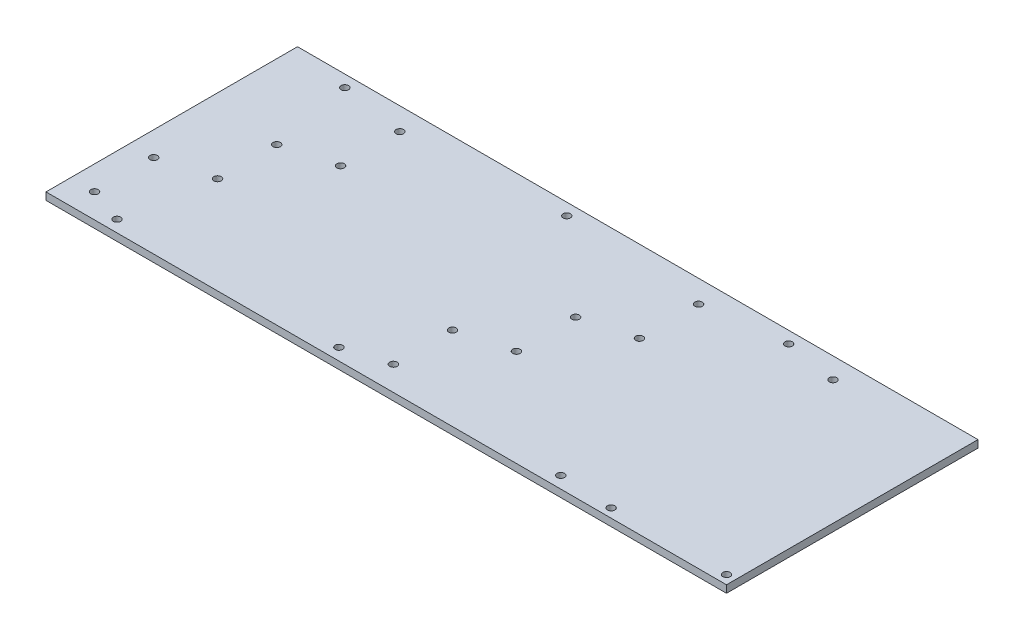
from build123d import *

# Parameters (mm, degrees)
SKIZZE1_W                       = 370
SKIZZE1_H                       = 165
AUFSATZ_LINEAR_AUSTRAGEN1_DEPTH = 5
M6_GEWINDEBOHRUNG1_D            = 5
M6_GEWINDEBOHRUNG1_DEPTH        = 5
SKIZZE5_W                       = 165
SKIZZE5_H                       = 5
AUFSATZ_LINEAR_AUSTRAGEN2_DEPTH = 90
SKIZZE9_W                       = 460
SKIZZE9_H                       = 5
AUFSATZ_LINEAR_AUSTRAGEN3_DEPTH = 3.17
M6_GEWINDEBOHRUNG2_D            = 5
M6_GEWINDEBOHRUNG2_DEPTH        = 5
SKIZZE12_W                      = 460
SKIZZE12_H                      = 5
AUFSATZ_LINEAR_AUSTRAGEN4_DEPTH = 1.83
M6_GEWINDEBOHRUNG3_D            = 5
M6_GEWINDEBOHRUNG3_DEPTH        = 5


with BuildPart() as part:
    # Skizze1 → Aufsatz-Linear austragen1 (new body)
    with BuildSketch(Plane(origin=(0, 0, 0), x_dir=(1, 0, 0), z_dir=(0, 1, 0))):
        Rectangle(SKIZZE1_W, SKIZZE1_H)
    extrude(amount=AUFSATZ_LINEAR_AUSTRAGEN1_DEPTH)

    # M6 Gewindebohrung1
    with Locations(Plane(origin=(0, 5, 0), x_dir=(1, 0, 0), z_dir=(0, 1, 0))):
        with Locations((67.3, -20), (67.3, 20), (-134.7, -20), (-134.7, 20), (101.3, 69.17), (-100.7, 29.17), (101.3, 29.17), (-100.7, 69.17), (33.3, -69.17), (-168.7, -29.17), (33.3, -29.17), (-168.7, -69.17)):
            Hole(M6_GEWINDEBOHRUNG1_D / 2, depth=M6_GEWINDEBOHRUNG1_DEPTH)

    # Skizze5 → Aufsatz-Linear austragen2 (add)
    with BuildSketch(Plane(origin=(185, 0, 0), x_dir=(0, 0, -1), z_dir=(1, 0, 0))):
        with Locations((0, 2.5)):
            Rectangle(SKIZZE5_W, SKIZZE5_H)
    extrude(amount=AUFSATZ_LINEAR_AUSTRAGEN2_DEPTH)

    # Skizze9 → Aufsatz-Linear austragen3 (add)
    with BuildSketch(Plane.XY.offset(82.5)):
        with Locations((45, 2.5)):
            Rectangle(SKIZZE9_W, SKIZZE9_H)
    extrude(amount=AUFSATZ_LINEAR_AUSTRAGEN3_DEPTH)

    # M6 Gewindebohrung2
    with Locations(Plane(origin=(0, 5, 0), x_dir=(1, 0, 0), z_dir=(0, 1, 0))):
        with Locations((191, 70.33), (191, -79.67), (269, -79.67)):
            Hole(M6_GEWINDEBOHRUNG2_D / 2, depth=M6_GEWINDEBOHRUNG2_DEPTH)

    # Skizze12 → Aufsatz-Linear austragen4 (add)
    with BuildSketch(Plane(origin=(0, 0, -82.5), x_dir=(-1, 0, 0), z_dir=(0, 0, -1))):
        with Locations((-45, 2.5)):
            Rectangle(SKIZZE12_W, SKIZZE12_H)
    extrude(amount=AUFSATZ_LINEAR_AUSTRAGEN4_DEPTH)

    # M6 Gewindebohrung3
    with Locations(Plane(origin=(0, 5, 0), x_dir=(1, 0, 0), z_dir=(0, 1, 0))):
        with Locations((-145, -77.67), (-145, 76.33), (5, -77.67), (5, 76.33), (155, -77.67), (155, 76.33)):
            Hole(M6_GEWINDEBOHRUNG3_D / 2, depth=M6_GEWINDEBOHRUNG3_DEPTH)


solid = part.part
